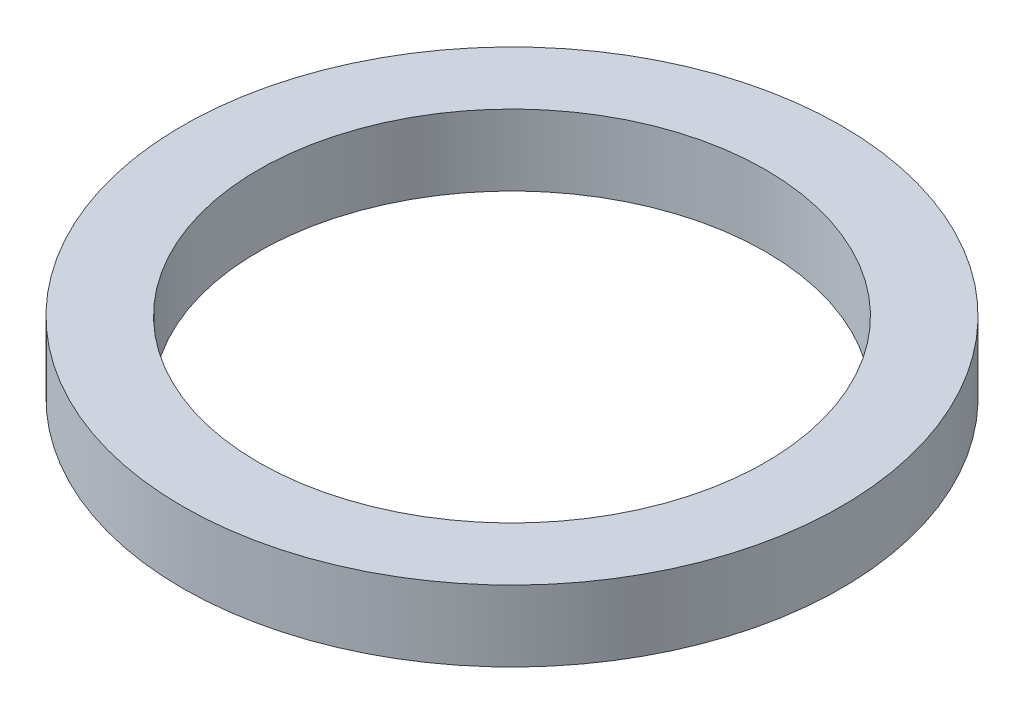
from build123d import *

# Parameters (mm, degrees)
SKETCH1_R           = 32.5
SKETCH1_R_2         = 25
BOSS_EXTRUDE1_DEPTH = 3.5


with BuildPart() as part:
    # Sketch1 → Boss-Extrude1 (new body, symmetric)
    with BuildSketch(Plane(origin=(0, 0, 0), x_dir=(1, 0, 0), z_dir=(0, 1, 0))):
        Circle(SKETCH1_R)
        Circle(SKETCH1_R_2, mode=Mode.SUBTRACT)
    extrude(amount=BOSS_EXTRUDE1_DEPTH, both=True)


solid = part.part
